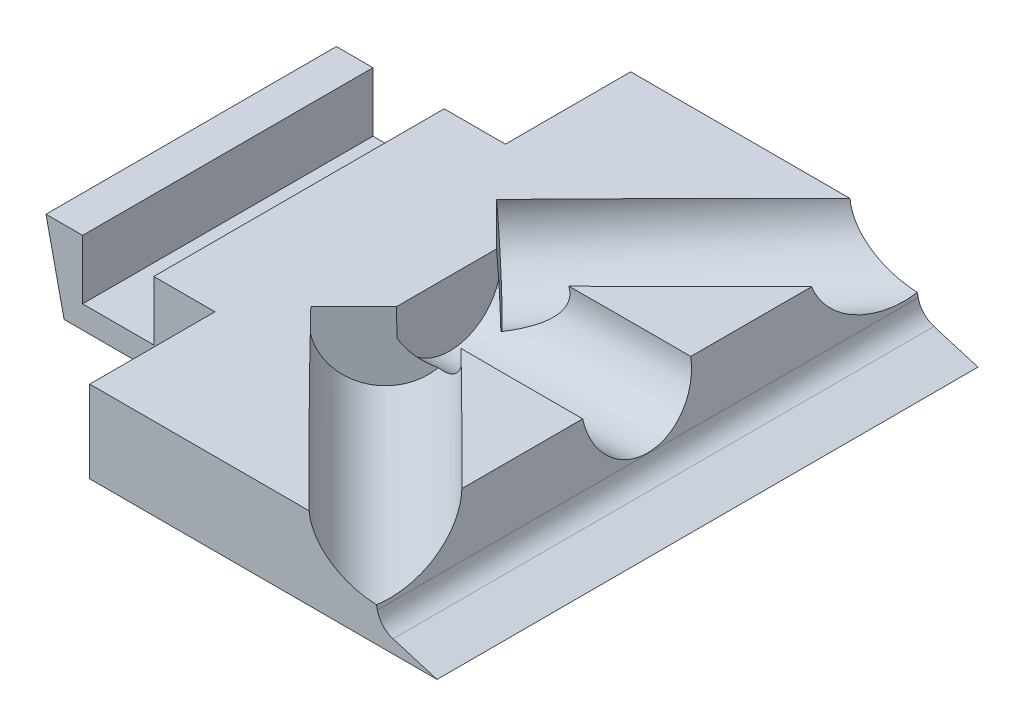
from build123d import *

# Parameters (mm, degrees)
SKETCH1_W           = 95
SKETCH1_H           = 95
BOSS_EXTRUDE1_DEPTH = 50
CUT_EXTRUDE1_DEPTH  = 100
SKETCH3_R           = 9.5
CUT_EXTRUDE2_DEPTH  = 45
CUT_EXTRUDE4_DEPTH  = 45
CUT_EXTRUDE5_DEPTH  = 45
CUT_EXTRUDE6_DEPTH  = 45
CUT_EXTRUDE7_DEPTH  = 45
SKETCH9_R           = 9.5
CUT_EXTRUDE9_DEPTH  = 45
SKETCH11_R          = 9.5
CUT_EXTRUDE10_DEPTH = 45
SKETCH12_W          = 31.985759797
SKETCH12_H          = 95
BOSS_EXTRUDE2_DEPTH = 45
CUT_EXTRUDE11_DEPTH = 100
SKETCH14_R          = 9.5
CUT_EXTRUDE12_DEPTH = 100
SKETCH15_R          = 9.5
CUT_EXTRUDE13_DEPTH = 100
SKETCH16_R          = 9.5
CUT_EXTRUDE14_DEPTH = 100
FILLET2_R           = 4
SKETCH17_W          = 34
SKETCH17_H          = 34
CUT_EXTRUDE16_DEPTH = 22
SKETCH19_W          = 34
SKETCH19_H          = 34
CUT_EXTRUDE17_DEPTH = 22
SKETCH20_W          = 12.5
SKETCH20_H          = 16.5
CUT_EXTRUDE18_DEPTH = 60
CUT_EXTRUDE19_DEPTH = 60
CUT_EXTRUDE20_DEPTH = 100


with BuildPart() as part:
    # Sketch1 → Boss-Extrude1 (new body)
    with BuildSketch(Plane(origin=(0, 0, 0), x_dir=(1, 0, 0), z_dir=(0, 1, 0))):
        with Locations((-8.446550514, 2.043801884)):
            Rectangle(SKETCH1_W, SKETCH1_H)
    extrude(amount=BOSS_EXTRUDE1_DEPTH)

    # Sketch2 → Cut-Extrude1 (cut)
    with BuildSketch(Plane.XY.offset(45.456198116)):
        Polygon((39.053449486, 0), (36.353449486, 50), (39.053449486, 50), align=None)
    extrude(amount=-CUT_EXTRUDE1_DEPTH, mode=Mode.SUBTRACT)

    # Sketch3 → Cut-Extrude2 (cut)
    with BuildSketch(Plane(origin=(38.939900735, 2.10275464, 0), x_dir=(0, 0, -1), z_dir=(0.998545181, 0.05392144, 0))):
        with Locations((2.043801884, 13.394181776)):
            Circle(SKETCH3_R)
    extrude(amount=-CUT_EXTRUDE2_DEPTH, mode=Mode.SUBTRACT)

    # Sketch5 → Cut-Extrude4 (cut)
    with BuildSketch(Plane(origin=(0, 50, 0), x_dir=(1, 0, 0), z_dir=(0, 1, 0))):
        Polygon((39.053449486, 49.543801884), (39.053449486, 29.543801884), (19.053449486, 49.543801884), align=None)
        Polygon((39.053449486, -45.456198116), (39.053449486, -25.456198116), (19.053449486, -45.456198116), align=None)
    extrude(amount=-CUT_EXTRUDE4_DEPTH, mode=Mode.SUBTRACT)

    # Sketch6 → Cut-Extrude5 (cut)
    with BuildSketch(Plane(origin=(0, 50, 0), x_dir=(1, 0, 0), z_dir=(0, 1, 0))):
        Polygon((19.053449486, -45.456198116), (12.925569587, -39.328318218), (6.797689689, -45.456198116), align=None)
        Polygon((19.053449486, 49.543801884), (12.925569587, 43.415921985), (6.797689689, 49.543801884), align=None)
    extrude(amount=-CUT_EXTRUDE5_DEPTH, mode=Mode.SUBTRACT)

    # Sketch7 → Cut-Extrude6 (cut)
    with BuildSketch(Plane(origin=(-13.201374315, 0, 13.201374315), x_dir=(0.707106781, 0, 0.707106781), z_dir=(-0.707106781, 0, 0.707106781))):
        Polygon((45.615209271, 5), (42.915209271, 50), (45.615209271, 50), align=None)
    extrude(amount=-CUT_EXTRUDE6_DEPTH, mode=Mode.SUBTRACT)

    # Sketch8 → Cut-Extrude7 (cut)
    with BuildSketch(Plane(origin=(-15.245176199, 0, -15.245176199), x_dir=(-0.707106781, 0, 0.707106781), z_dir=(-0.707106781, 0, -0.707106781))):
        Polygon((-48.505581614, 5), (-45.805581614, 50), (-48.505581614, 50), align=None)
    extrude(amount=-CUT_EXTRUDE7_DEPTH, mode=Mode.SUBTRACT)

    # Sketch9 → Cut-Extrude9 (cut)
    with BuildSketch(Plane(origin=(34.386964646, 2.917830706, -34.386964646), x_dir=(-0.708373873, 0.059677836, -0.70331004), z_dir=(0.705837415, 0.059892291, -0.705837415))):
        with Locations((14.526974541, 11.311121921)):
            Circle(SKETCH9_R)
    extrude(amount=-CUT_EXTRUDE9_DEPTH, mode=Mode.SUBTRACT)

    # Sketch11 → Cut-Extrude10 (cut)
    with BuildSketch(Plane(origin=(32.350494057, 2.745030447, 32.350494057), x_dir=(0.70331004, 0.059677836, -0.708373873), z_dir=(0.705837415, 0.059892291, 0.705837415))):
        with Locations((-10.17752107, 12.964151979)):
            Circle(SKETCH11_R)
    extrude(amount=-CUT_EXTRUDE10_DEPTH, mode=Mode.SUBTRACT)

    # Sketch12 → Boss-Extrude2 (add)
    with BuildSketch(Plane(origin=(0, 5, 0), x_dir=(1, 0, 0), z_dir=(0, 1, 0))):
        with Locations((22.790569588, 2.043801884)):
            Rectangle(SKETCH12_W, SKETCH12_H)
    extrude(amount=BOSS_EXTRUDE2_DEPTH)

    # Sketch13 → Cut-Extrude11 (cut)
    with BuildSketch(Plane.XY.offset(45.456198116)):
        Polygon((39.053449486, 0), (29.053449486, 3), (19.053449486, 50), (49.745275601, 50), align=None)
    extrude(amount=-CUT_EXTRUDE11_DEPTH, mode=Mode.SUBTRACT)

    # Sketch14 → Cut-Extrude12 (cut)
    with BuildSketch(Plane(origin=(-5.994632406, -0.32371015, 0), x_dir=(0, 0, -1), z_dir=(0.998545181, 0.05392144, 0))):
        with Locations((2.043801884, 13.394181776)):
            Circle(SKETCH14_R)
    extrude(amount=CUT_EXTRUDE12_DEPTH, mode=Mode.SUBTRACT)

    # Sketch15 → Cut-Extrude13 (cut)
    with BuildSketch(Plane(origin=(0.587810371, 0.049877364, 0.587810371), x_dir=(0.70331004, 0.059677836, -0.708373873), z_dir=(0.705837415, 0.059892291, 0.705837415))):
        with Locations((-10.17752107, 12.964151979)):
            Circle(SKETCH15_R)
    extrude(amount=CUT_EXTRUDE13_DEPTH, mode=Mode.SUBTRACT)

    # Sketch16 → Cut-Extrude14 (cut)
    with BuildSketch(Plane(origin=(2.62428096, 0.222677624, -2.62428096), x_dir=(-0.708373873, 0.059677836, -0.70331004), z_dir=(0.705837415, 0.059892291, -0.705837415))):
        with Locations((14.526974541, 11.311121921)):
            Circle(SKETCH16_R)
    extrude(amount=CUT_EXTRUDE14_DEPTH, mode=Mode.SUBTRACT)

    # Fillet2
    fillet2_edges = [part.edges().sort_by_distance(p)[0] for p in [
        (29.053449486, 3, -2.043801884),
    ]]
    fillet(fillet2_edges, radius=FILLET2_R)

    # Sketch17 → Cut-Extrude16 (cut)
    with BuildSketch(Plane.XY.offset(45.456198116)):
        with Locations((-38.946550514, 17)):
            Rectangle(SKETCH17_W, SKETCH17_H)
    extrude(amount=-CUT_EXTRUDE16_DEPTH, mode=Mode.SUBTRACT)

    # Sketch19 → Cut-Extrude17 (cut)
    with BuildSketch(Plane(origin=(0, 0, -49.543801884), x_dir=(-1, 0, 0), z_dir=(0, 0, -1))):
        with Locations((38.946550514, 17)):
            Rectangle(SKETCH19_W, SKETCH19_H)
    extrude(amount=-CUT_EXTRUDE17_DEPTH, mode=Mode.SUBTRACT)

    # Sketch20 → Cut-Extrude18 (cut)
    with BuildSketch(Plane.XY.offset(23.456198116)):
        with Locations((-38.946550514, 12.25)):
            Rectangle(SKETCH20_W, SKETCH20_H)
    extrude(amount=-CUT_EXTRUDE18_DEPTH, mode=Mode.SUBTRACT)

    # Sketch21 → Cut-Extrude19 (cut)
    with BuildSketch(Plane.XY.offset(23.456198116)):
        Polygon((-55.946550514, 34), (-48.446550514, 0), (-55.946550514, 0), align=None)
    extrude(amount=-CUT_EXTRUDE19_DEPTH, mode=Mode.SUBTRACT)

    # Sketch22 → Cut-Extrude20 (cut)
    with BuildSketch(Plane.XY.offset(45.456198116)):
        Polygon((16.581652311, 14.417739075), (-57.762384818, 14.417739075), (-57.762384818, 55.877932289), (42.054048577, 55.877932289), (42.054048577, 14.417739075), align=None)
    extrude(amount=-CUT_EXTRUDE20_DEPTH, mode=Mode.SUBTRACT)


solid = part.part
